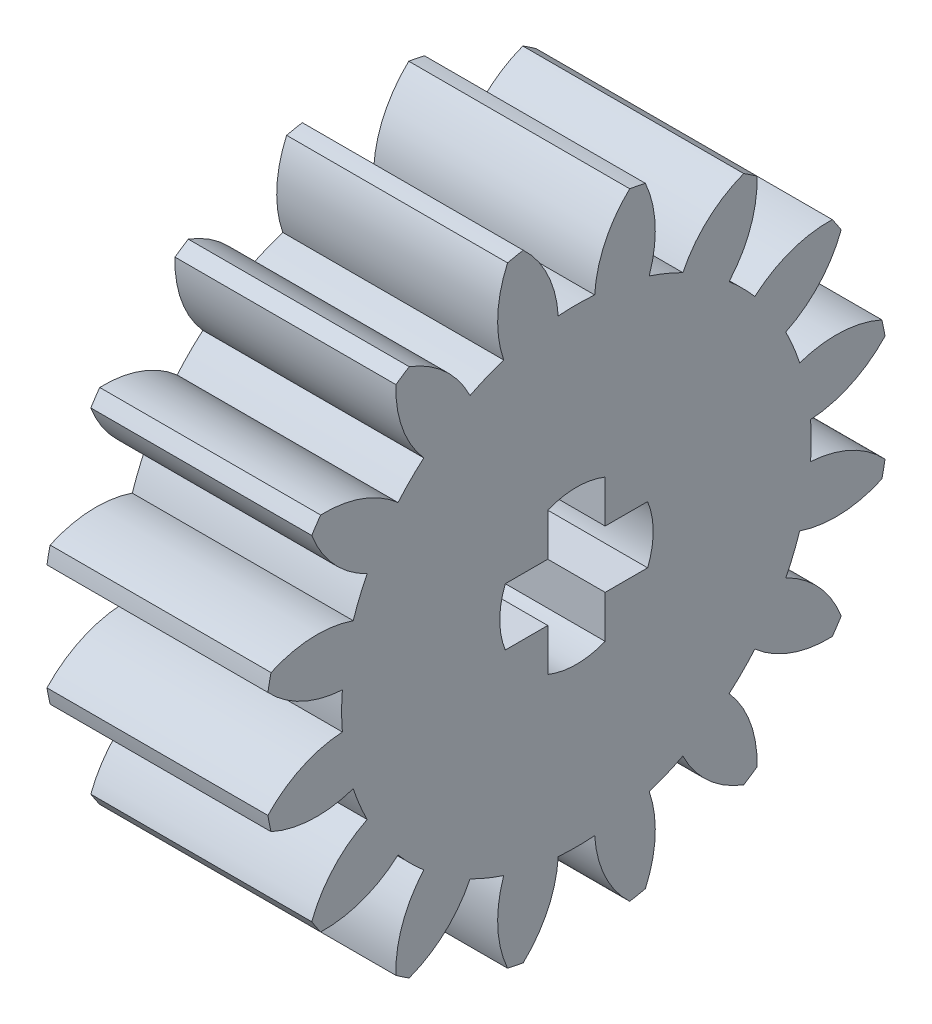
from build123d import *

# Parameters (mm, degrees)
BASPROSKE_W        = 6.35
BASPROSKE_H        = 9
TOOTHCUT_DEPTH     = 15.224011389
TEETHCUTS_COUNT    = 16
TEETHCUTS_ANGLE    = 337.5
BORSKE_R           = 0.5
BORE_DEPTH         = 50.0000508
CUT_EXTRUDE1_DEPTH = 10


with BuildPart() as part:
    # BasProSke → Base-Revolve (revolve)
    with BuildSketch(Plane(origin=(0, 0, 0), x_dir=(1, 0, 0), z_dir=(0, 1, 0)), mode=Mode.PRIVATE) as base_revolve_sk:
        with Locations((3.175, 4.5)):
            Rectangle(BASPROSKE_W, BASPROSKE_H)
    revolve(base_revolve_sk.sketch.rotate(Axis((-10, 0, 0), (1, 0, 0)), 180), axis=Axis((-10, 0, 0), (1, 0, 0)))

    # TooCutSke → ToothCut (cut, through all)
    with BuildSketch(Plane(origin=(0, 0, 0), x_dir=(0, 0, -1), z_dir=(1, 0, 0))):
        with BuildLine():
            ThreePointArc((0.523792937, 6.728643397), (0, 6.749), (-0.523792937, 6.728643397))
            ThreePointArc((-0.523792937, 6.728643397), (-0.828704482, 7.90962059), (-1.553355277, 8.890721711))
            ThreePointArc((-1.553355277, 8.890721711), (0, 9.0254), (1.553355277, 8.890721711))
            ThreePointArc((1.553355277, 8.890721711), (0.828704482, 7.90962059), (0.523792937, 6.728643397))
        make_face()
    toothcut = extrude(amount=TOOTHCUT_DEPTH, mode=Mode.SUBTRACT)

    # TeethCuts: ToothCut ×16 about axis
    teethcuts_axis = Axis((-10, 0, 0), (1, 0, 0))
    for i in range(1, TEETHCUTS_COUNT):
        add(toothcut.rotate(teethcuts_axis, i * TEETHCUTS_ANGLE / (TEETHCUTS_COUNT - 1)), mode=Mode.SUBTRACT)

    # BorSke → Bore (cut, symmetric)
    with BuildSketch(Plane(origin=(0, 0, 0), x_dir=(0, 0, -1), z_dir=(1, 0, 0))):
        with Locations(Location((0, 0, 0), (0, 0, 180))):
            Circle(BORSKE_R)
    extrude(amount=BORE_DEPTH, both=True, mode=Mode.SUBTRACT)

    # Sketch1 → Cut-Extrude1 (cut)
    with BuildSketch(Plane(origin=(6.35, 0, 0), x_dir=(0, 0, -1), z_dir=(1, 0, 0))):
        with BuildLine():
            ThreePointArc((0.824891111, 2.044891111), (0, 2.205), (-0.824891111, 2.044891111))
            Line((-0.824891111, 2.044891111), (-0.824891111, 0.824891111))
            Line((-0.824891111, 0.824891111), (-2.044891111, 0.824891111))
            ThreePointArc((-2.044891111, 0.824891111), (-2.205, 0), (-2.044891111, -0.824891111))
            Line((-2.044891111, -0.824891111), (-0.824891111, -0.824891111))
            Line((-0.824891111, -0.824891111), (-0.824891111, -2.044891111))
            ThreePointArc((-0.824891111, -2.044891111), (0, -2.205), (0.824891111, -2.044891111))
            Line((0.824891111, -2.044891111), (0.824891111, -0.824891111))
            Line((0.824891111, -0.824891111), (2.044891111, -0.824891111))
            ThreePointArc((2.044891111, -0.824891111), (2.164602723, -0.420142893), (2.205, 0))
            ThreePointArc((2.205, 0), (2.164602723, 0.420142893), (2.044891111, 0.824891111))
            Line((2.044891111, 0.824891111), (0.824891111, 0.824891111))
            Line((0.824891111, 0.824891111), (0.824891111, 2.044891111))
        make_face()
    extrude(amount=-CUT_EXTRUDE1_DEPTH, mode=Mode.SUBTRACT)


solid = part.part
